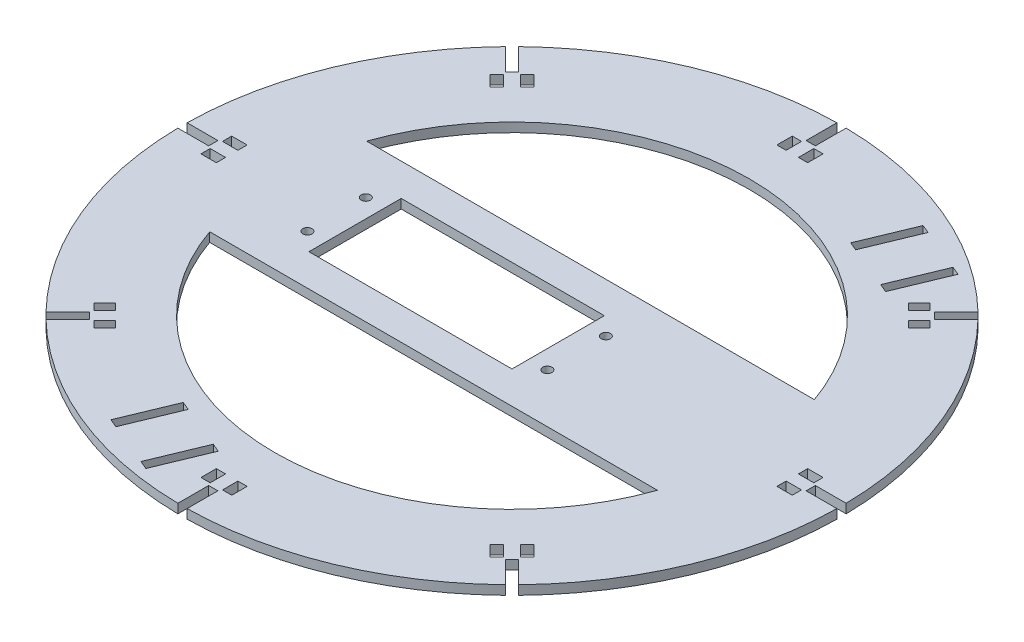
from build123d import *

# Parameters (mm, degrees)
SKETCH1_R           = 107.09
BOSS_EXTRUDE1_DEPTH = 3
CUT_EXTRUDE1_START  = -3
CUT_EXTRUDE1_DEPTH  = 4
CIRPATTERN1_COUNT   = 8
SKETCH7_W           = 3
SKETCH7_H           = 5
CUT_EXTRUDE4_DEPTH  = 3
CIRPATTERN2_COUNT   = 8
SKETCH4_R           = 1.5
SKETCH4_W           = 66
SKETCH4_H           = 30
CUT_EXTRUDE5_DEPTH  = 10
CUT_EXTRUDE6_DEPTH  = 3


with BuildPart() as part:
    # Sketch1 → Boss-Extrude1 (new body)
    with BuildSketch(Plane(origin=(0, 0, 0), x_dir=(1, 0, 0), z_dir=(0, 1, 0))):
        Circle(SKETCH1_R)
    extrude(amount=BOSS_EXTRUDE1_DEPTH)

    # Sketch2 → Cut-Extrude1 (cut)
    with BuildSketch(Plane(origin=(0, 3, 0), x_dir=(1, 0, 0), z_dir=(0, 1, 0)).offset(CUT_EXTRUDE1_START)):
        Polygon((-1.5, 597.330930071), (-1.5, 107.079494302), (-1.5, 97.079494302), (1.5, 97.079494302), (1.5, 107.079494302), (1.5, 597.330930071), (1.5, 1577.83380161), (-1.5, 1577.83380161), align=None)
    cut_extrude1 = extrude(amount=CUT_EXTRUDE1_DEPTH, mode=Mode.SUBTRACT)

    # CirPattern1: Cut-Extrude1 ×8 about axis
    cirpattern1_axis = Axis((0, 0, 0), (0, -1, 0))
    for i in range(1, CIRPATTERN1_COUNT):
        add(cut_extrude1.rotate(cirpattern1_axis, i * 360 / CIRPATTERN1_COUNT), mode=Mode.SUBTRACT)

    # Sketch7 → Cut-Extrude4 (cut)
    with BuildSketch(Plane(origin=(0, 3, 0), x_dir=(1, 0, 0), z_dir=(0, 1, 0))):
        with Locations((-3.5, 93.579494302)):
            Rectangle(SKETCH7_W, SKETCH7_H)
        with Locations((3.5, 93.579494302)):
            Rectangle(SKETCH7_W, SKETCH7_H)
    cut_extrude4 = extrude(amount=-CUT_EXTRUDE4_DEPTH, mode=Mode.SUBTRACT)

    # CirPattern2: Cut-Extrude4 ×8 about axis
    cirpattern2_axis = Axis((0, 0, 0), (0, 1, 0))
    for i in range(1, CIRPATTERN2_COUNT):
        add(cut_extrude4.rotate(cirpattern2_axis, i * 360 / CIRPATTERN2_COUNT), mode=Mode.SUBTRACT)

    # Sketch4 → Cut-Extrude5 (cut)
    with BuildSketch(Plane(origin=(0, 3, 0), x_dir=(1, 0, 0), z_dir=(0, 1, 0))):
        with Locations((-57, 9.5)):
            Circle(SKETCH4_R)
        with Locations((-57, -9.5)):
            Circle(SKETCH4_R)
        with Locations((21, -9.5)):
            Circle(SKETCH4_R)
        with Locations((21, 9.5)):
            Circle(SKETCH4_R)
        with Locations((-18, 0)):
            Rectangle(SKETCH4_W, SKETCH4_H)
        with BuildLine():
            Line((72.75038213, -25.5), (-72.75038213, -25.5))
            ThreePointArc((-72.75038213, -25.5), (0, -77.09), (72.75038213, -25.5))
        make_face()
        with BuildLine():
            Line((72.75038213, 25.5), (-72.75038213, 25.5))
            ThreePointArc((-72.75038213, 25.5), (0, 77.09), (72.75038213, 25.5))
        make_face()
    extrude(amount=-CUT_EXTRUDE5_DEPTH, mode=Mode.SUBTRACT)

    # Sketch9 → Cut-Extrude6 (cut)
    with BuildSketch(Plane(origin=(0, 3, 0), x_dir=(1, 0, 0), z_dir=(0, 1, 0))):
        Polygon((-35.879388071, -94.459883081), (-33.107749474, -95.607933378), (-26.219447691, -78.978101793), (-28.991086289, -77.830051496), align=None)
        Polygon((-19.249556486, -101.348184863), (-16.477917889, -102.49623516), (-9.589616106, -85.866403575), (-12.361254704, -84.718353278), align=None)
        Polygon((53.935833667, 67.497598822), (60.824135449, 84.127430407), (58.052496852, 85.275480704), (51.164195069, 68.645649119), align=None)
        Polygon((37.306002081, 74.385900604), (44.194303864, 91.015732189), (41.422665266, 92.163782487), (34.534363484, 75.533950901), align=None)
    extrude(amount=-CUT_EXTRUDE6_DEPTH, mode=Mode.SUBTRACT)


solid = part.part
